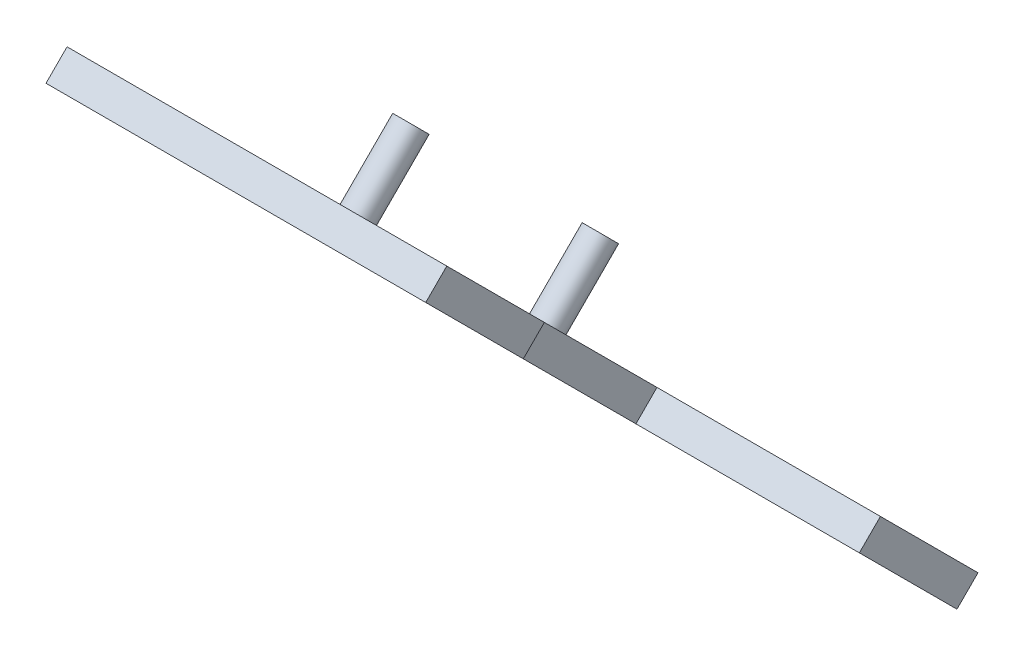
from build123d import *

# Parameters (mm, degrees)
BOSS_EXTRUDE1_START      = -23110
BOSS_EXTRUDE1_DEPTH      = 5
BOSS_EXTRUDE1_DEPTH_BACK = 100
SKETCH3_W                = 150.118051911
SKETCH3_H                = 92.714651823
BOSS_EXTRUDE2_DEPTH      = 20
SKETCH4_R                = 10
BOSS_EXTRUDE3_DEPTH      = 50


with BuildPart() as part:
    # Sketch2 → Boss-Extrude1 (new body, two sides)
    with BuildSketch(Plane(origin=(0, 0, 0), x_dir=(0, 0, -1), z_dir=(1, 0, 0)).offset(BOSS_EXTRUDE1_START)) as boss_extrude1_sk:
        Polygon((-40429.816686048, 2996.894248022), (-40415.674550424, 3011.036383646), (-40415.674550424, 2982.752112399), align=None)
        Polygon((-40072.930236915, 2640.00779889), (-40415.674550424, 2982.752112399), (-40415.674550424, 3011.036383646), (-40072.930236915, 2668.292070137), align=None)
        Polygon((-40058.788101291, 2654.149934513), (-40072.930236915, 2640.00779889), (-40072.930236915, 2668.292070137), align=None)
    extrude(amount=BOSS_EXTRUDE1_DEPTH)
    extrude(boss_extrude1_sk.sketch, amount=-BOSS_EXTRUDE1_DEPTH_BACK)

    # Sketch3 → Boss-Extrude2 (add)
    with BuildSketch(Plane(origin=(0, -18716.461219013, 18716.461219015), x_dir=(1, 0, 0), z_dir=(0, -0.707106781, 0.707106781))):
        with Locations((-23029.940974045, 30660.964460197)):
            Rectangle(SKETCH3_W, SKETCH3_H)
        with Locations((-23029.940974045, 30248.965455429)):
            Rectangle(SKETCH3_W, SKETCH3_H)
    extrude(amount=-BOSS_EXTRUDE2_DEPTH)

    # Sketch4 → Boss-Extrude3 (add)
    with BuildSketch(Plane(origin=(0, -18702.319083389, 18702.319083389), x_dir=(1, 0, 0), z_dir=(0, 0.707106781, -0.707106781))):
        with Locations((-23146.230449039, -30340.794679614)):
            Circle(SKETCH4_R)
        with Locations((-23146.230449039, -30520.794679614)):
            Circle(SKETCH4_R)
    extrude(amount=BOSS_EXTRUDE3_DEPTH)


solid = part.part
